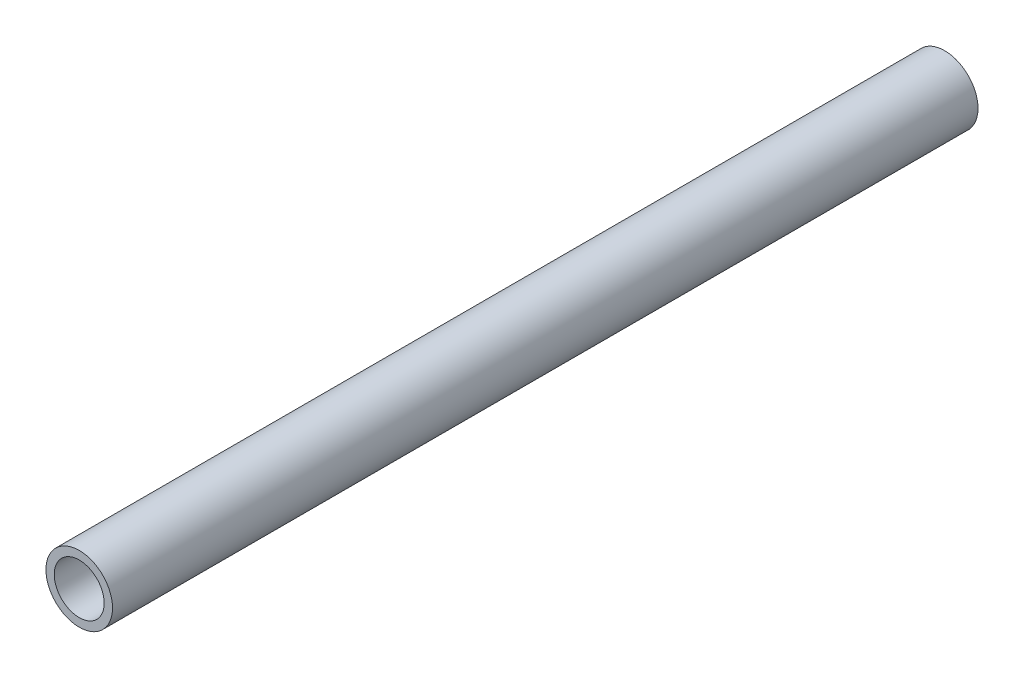
from build123d import *

# Parameters (mm, degrees)
SKETCH2_R           = 40
SKETCH2_R_2         = 30
BOSS_EXTRUDE1_DEPTH = 1040


with BuildPart() as part:
    # Sketch2 → Boss-Extrude1 (new body)
    with BuildSketch(Plane.XY):
        Circle(SKETCH2_R)
        Circle(SKETCH2_R_2, mode=Mode.SUBTRACT)
    extrude(amount=BOSS_EXTRUDE1_DEPTH)


solid = part.part
